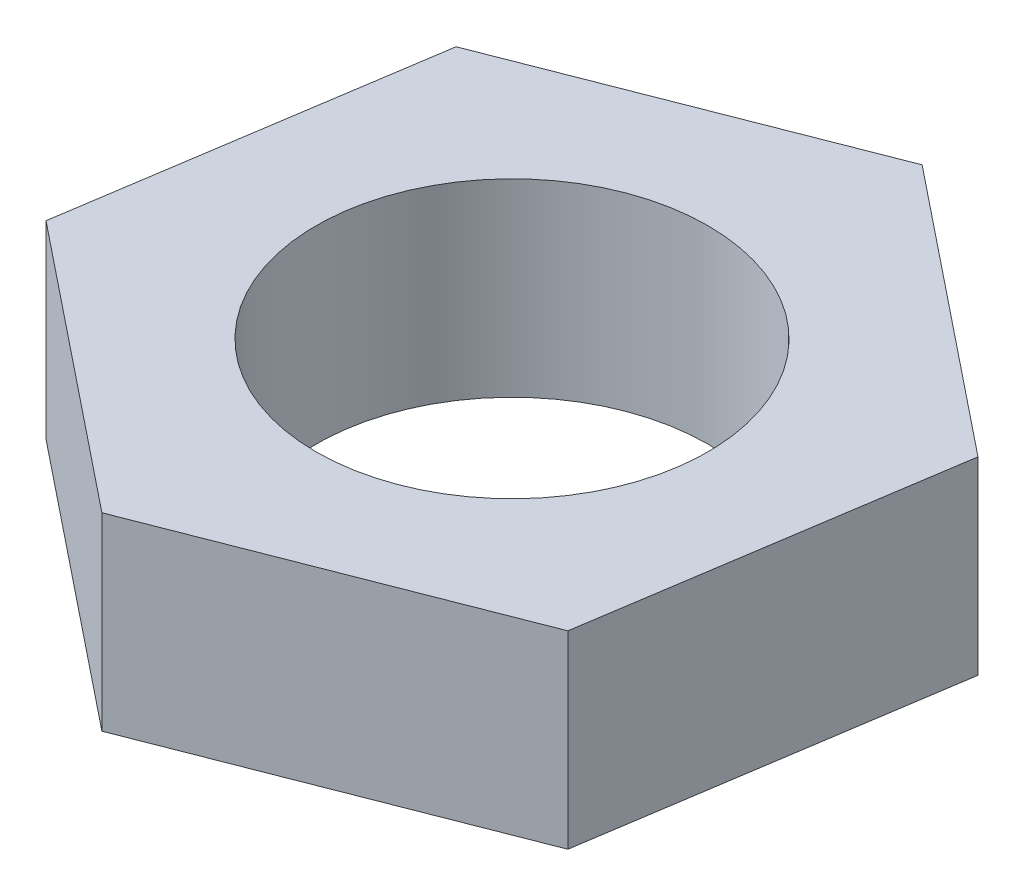
from build123d import *

# Parameters (mm, degrees)
BOSS_EXTRU_1_DEPTH      = 7
ESQUISSE2_R             = 7.25
ENL_V_MAT_EXTRU_1_DEPTH = 7


with BuildPart() as part:
    # Esquisse1 → Boss.-Extru.1 (new body)
    with BuildSketch(Plane(origin=(0, 0, 0), x_dir=(1, 0, 0), z_dir=(0, 1, 0))):
        Polygon((-12.405020583, -4.837958027), (-2.012715737, -13.162041973), (10.392304845, -8.324083945), (12.405020583, 4.837958027), (2.012715737, 13.162041973), (-10.392304845, 8.324083945), align=None)
    extrude(amount=BOSS_EXTRU_1_DEPTH)

    # Esquisse2 → Enlèv. mat.-Extru.1 (cut)
    with BuildSketch(Plane(origin=(0, 7, 0), x_dir=(1, 0, 0), z_dir=(0, 1, 0))):
        Circle(ESQUISSE2_R)
    extrude(amount=-ENL_V_MAT_EXTRU_1_DEPTH, mode=Mode.SUBTRACT)


solid = part.part
